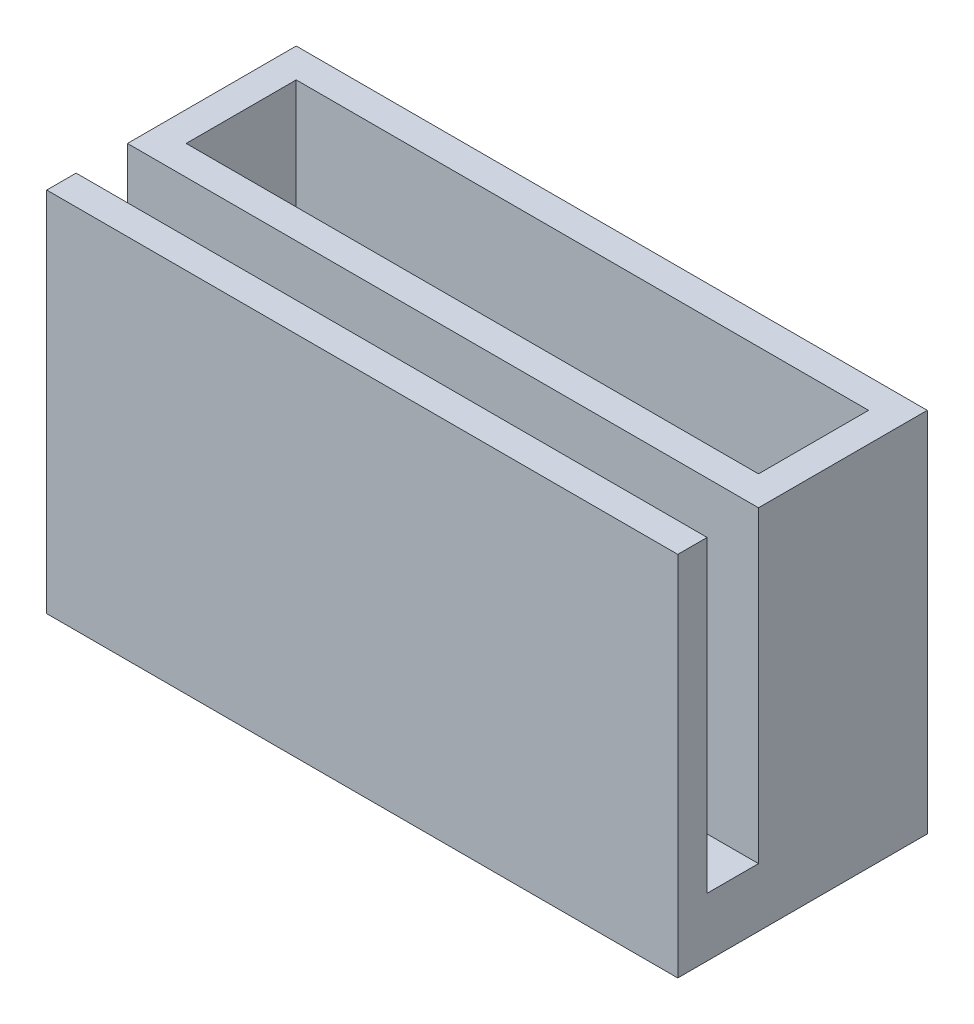
from build123d import *

# Parameters (mm, degrees)
SKETCH1_W           = 43
SKETCH1_H           = 11.5
SKETCH1_W_2         = 39
SKETCH1_H_2         = 7.5
BOSS_EXTRUDE1_DEPTH = 25
SKETCH2_W           = 43
SKETCH2_H           = 5.5
BOSS_EXTRUDE2_DEPTH = 4
SKETCH3_W           = 43
SKETCH3_H           = 2
BOSS_EXTRUDE3_DEPTH = 21


with BuildPart() as part:
    # Sketch1 → Boss-Extrude1 (new body)
    with BuildSketch(Plane(origin=(0, 0, 0), x_dir=(1, 0, 0), z_dir=(0, 1, 0))):
        with Locations((19.5, 3.75)):
            Rectangle(SKETCH1_W, SKETCH1_H)
        with Locations((19.5, 3.75)):
            Rectangle(SKETCH1_W_2, SKETCH1_H_2, mode=Mode.SUBTRACT)
    extrude(amount=BOSS_EXTRUDE1_DEPTH)

    # Sketch2 → Boss-Extrude2 (add)
    with BuildSketch(Plane.XZ):
        with Locations((19.5, 4.75)):
            Rectangle(SKETCH2_W, SKETCH2_H)
    extrude(amount=-BOSS_EXTRUDE2_DEPTH)

    # Sketch3 → Boss-Extrude3 (add)
    with BuildSketch(Plane(origin=(0, 4, 0), x_dir=(1, 0, 0), z_dir=(0, 1, 0))):
        with Locations((19.5, -6.5)):
            Rectangle(SKETCH3_W, SKETCH3_H)
    extrude(amount=BOSS_EXTRUDE3_DEPTH)


solid = part.part
